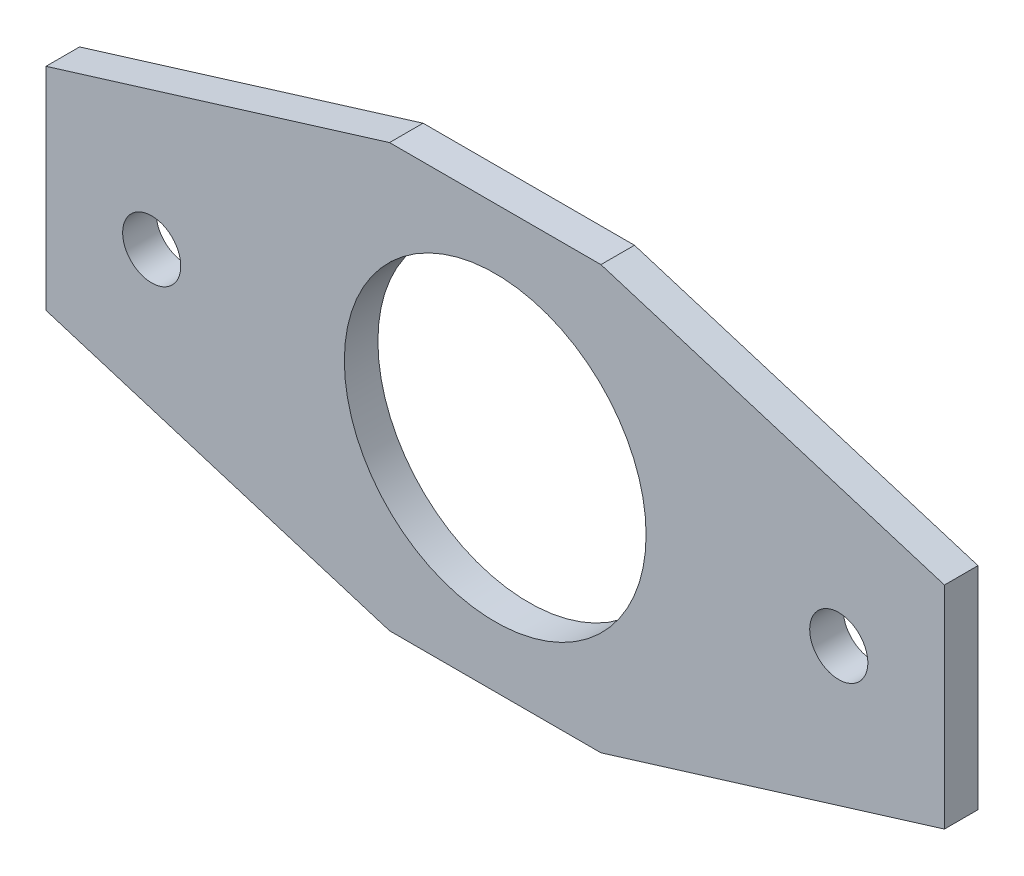
from build123d import *

# Parameters (mm, degrees)
SKETCH1_W           = 85
SKETCH1_H           = 40
BOSS_EXTRUDE1_DEPTH = 3.175
SKETCH2_R           = 14.275
CUT_EXTRUDE1_DEPTH  = 4.175
SKETCH4_OUTSIDE_W   = 105.8
SKETCH4_OUTSIDE_H   = 60.8
CUT_EXTRUDE4_DEPTH  = 4.175
SKETCH6_R           = 2.75
CUT_EXTRUDE6_DEPTH  = 4.175


with BuildPart() as part:
    # Sketch1 → Boss-Extrude1 (new body)
    with BuildSketch(Plane.XY):
        with Locations((42.5, 20)):
            Rectangle(SKETCH1_W, SKETCH1_H)
    extrude(amount=BOSS_EXTRUDE1_DEPTH)

    # Sketch2 → Cut-Extrude1 (cut, through all)
    with BuildSketch(Plane.XY.offset(3.175)):
        with Locations((42.5, 20)):
            Circle(SKETCH2_R)
    extrude(amount=-CUT_EXTRUDE1_DEPTH, mode=Mode.SUBTRACT)

    # Sketch4 outside → Cut-Extrude4 (cut, through all)
    with BuildSketch(Plane(origin=(0, 0, 0), x_dir=(-1, 0, 0), z_dir=(0, 0, -1))):
        with Locations((-42.5, 20)):
            Rectangle(SKETCH4_OUTSIDE_W, SKETCH4_OUTSIDE_H)
        Polygon((-32.5, 40), (0, 30), (0, 10), (-32.5, 0), (-52.5, 0), (-85, 10), (-85, 30), (-52.5, 40), align=None, mode=Mode.SUBTRACT)
    extrude(amount=-CUT_EXTRUDE4_DEPTH, mode=Mode.SUBTRACT)

    # Sketch6 → Cut-Extrude6 (cut, through all)
    with BuildSketch(Plane(origin=(0, 0, 0), x_dir=(-1, 0, 0), z_dir=(0, 0, -1))):
        with Locations((-75, 20)):
            Circle(SKETCH6_R)
        with Locations((-10, 20)):
            Circle(SKETCH6_R)
    extrude(amount=-CUT_EXTRUDE6_DEPTH, mode=Mode.SUBTRACT)


solid = part.part
